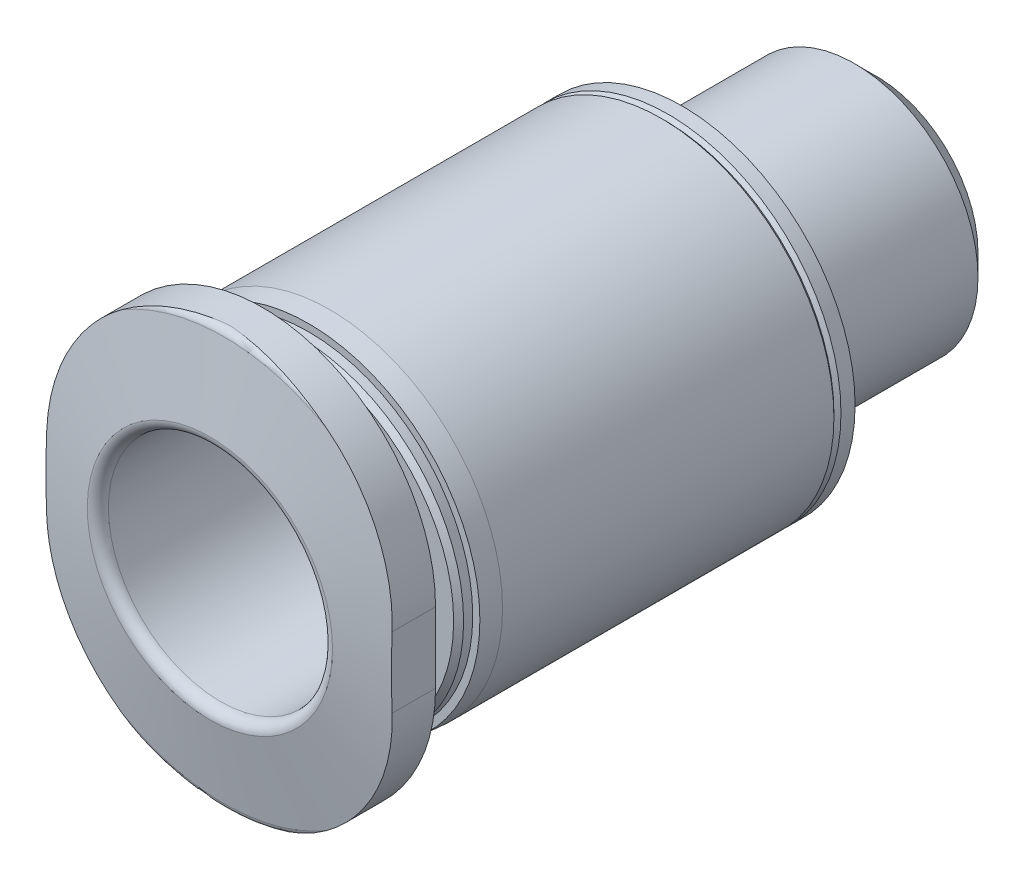
from build123d import *

# Parameters (mm, degrees)
SKIZZE2_W               = 23.6
SKIZZE2_H               = 23.6
LINEAR_AUSTRAGEN1_DEPTH = 1.5
LINEAR_AUSTRAGEN2_DEPTH = 7.2


with BuildPart() as part:
    # Skizze1 → Rotation1 (revolve)
    with BuildSketch(Plane(origin=(0, 0, 0), x_dir=(0, 0, -1), z_dir=(1, 0, 0))):
        with BuildLine():
            Line((-13.4, 0), (-13.4, 3.4785))
            Line((-13.4, 3.4785), (-13.002165841, 5.734729636))
            ThreePointArc((-13.002165841, 5.734729636), (-12.933761812, 5.853208889), (-12.80520429, 5.9))
            Line((-12.80520429, 5.9), (-11.9, 5.9))
            Line((-11.9, 5.9), (-11.9, 4.2535))
            ThreePointArc((-11.9, 4.2535), (-11.790165043, 3.988334957), (-11.525, 3.8785))
            Line((-11.525, 3.8785), (-11, 3.8785))
            Line((-11, 3.8785), (-11, 4.513578644))
            Line((-11, 4.513578644), (-10.858578644, 4.655))
            Line((-10.858578644, 4.655), (-10.6, 4.655))
            Line((-10.6, 4.655), (-10.6, 4.858043913))
            Line((-10.6, 4.858043913), (-10, 4.9))
            Line((-10, 4.9), (-0.6, 4.9))
            Line((-0.6, 4.9), (-0.5, 4.8))
            Line((-0.5, 4.8), (-0.4, 4.9))
            Line((-0.4, 4.9), (0, 4.9))
            Line((0, 4.9), (0, 3.5))
            Line((0, 3.5), (4.8865, 3.5))
            Line((4.8865, 3.5), (5.5, 2.8865))
            Line((5.5, 2.8865), (5.5, 0))
            Line((5.5, 0), (-13.4, 0))
        make_face()
    revolve(axis=Axis((0, 0, -5.5), (0, 0, 1)))

    # Skizze2 → Linear austragen1 (cut)
    with BuildSketch(Plane.XY.offset(13.4)):
        Rectangle(SKIZZE2_W, SKIZZE2_H)
        with BuildLine():
            Line((4.9, -1), (4.9, 1))
            ThreePointArc((4.9, 1), (0, 5.9), (-4.9, 1))
            Line((-4.9, 1), (-4.9, -1))
            ThreePointArc((-4.9, -1), (0, -5.9), (4.9, -1))
        make_face(mode=Mode.SUBTRACT)
    extrude(amount=-LINEAR_AUSTRAGEN1_DEPTH, mode=Mode.SUBTRACT)

    # Skizze3 → Linear austragen2 (cut)
    with BuildSketch(Plane.XY.offset(-5.5)):
        Polygon((-2, 1.154700538), (-2, -1.154700538), (0, -2.309401077), (2, -1.154700538), (2, 1.154700538), (0, 2.309401077), align=None)
    extrude(amount=LINEAR_AUSTRAGEN2_DEPTH, mode=Mode.SUBTRACT)

    # Skizze4 → Schnitt-Rotation1 (revolve, cut)
    with BuildSketch(Plane(origin=(0, 0, 0), x_dir=(0, 0, -1), z_dir=(1, 0, 0))):
        with BuildLine():
            Line((-13.4, 0), (-13.4, 3.4785))
            ThreePointArc((-13.4, 3.4785), (-13.312132034, 3.266367966), (-13.1, 3.1785))
            Line((-13.1, 3.1785), (-1.7, 3.1785))
            Line((-1.7, 3.1785), (-1.7, 0))
            Line((-1.7, 0), (-13.4, 0))
        make_face()
    revolve(axis=Axis((0, 0, 1.7), (0, 0, 1)), mode=Mode.SUBTRACT)


solid = part.part
